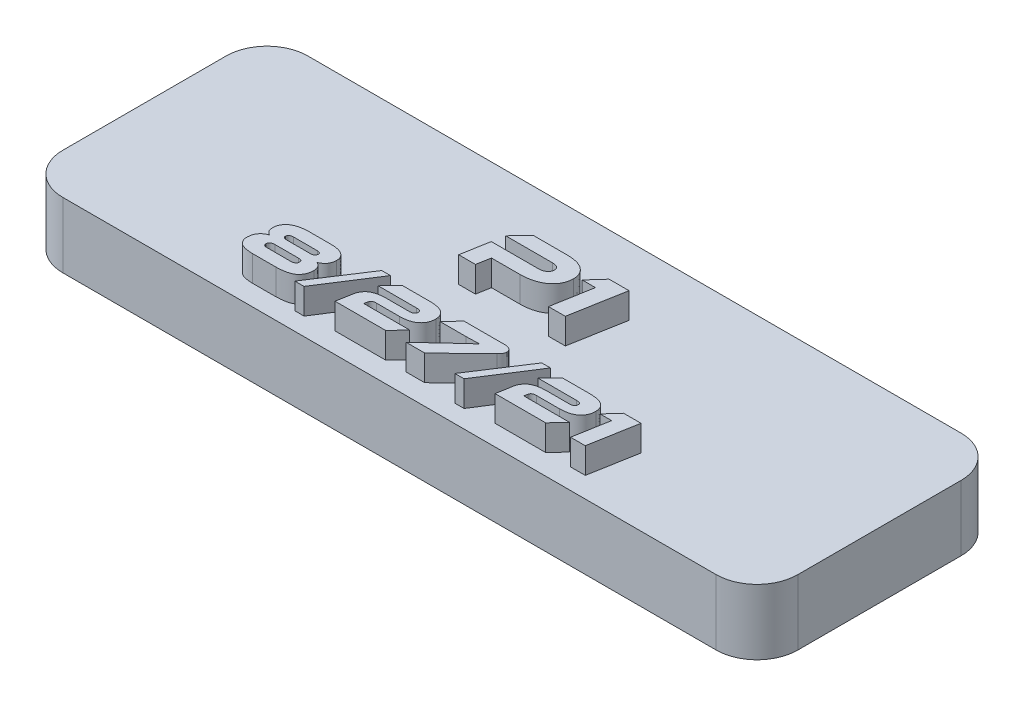
from build123d import *

# Parameters (mm, degrees)
SKETCH1_W           = 57.15
SKETCH1_H           = 19.05
BOSS_EXTRUDE1_DEPTH = 5.08
FILLET1_R           = 3.175
BOSS_EXTRUDE2_DEPTH = 2
SKETCH4_R           = 0.9
CUT_EXTRUDE1_DEPTH  = 4


with BuildPart() as part:
    # Sketch1 → Boss-Extrude1 (new body)
    with BuildSketch(Plane(origin=(0, 0, 0), x_dir=(1, 0, 0), z_dir=(0, 1, 0))):
        Rectangle(SKETCH1_W, SKETCH1_H)
    extrude(amount=BOSS_EXTRUDE1_DEPTH)

    # Fillet1
    fillet1_edges = [part.edges().sort_by_distance(p)[0] for p in [
        (-28.575, 2.54, -9.525),
        (-28.575, 2.54, 9.525),
        (28.575, 2.54, 9.525),
        (28.575, 2.54, -9.525),
    ]]
    fillet(fillet1_edges, radius=FILLET1_R)

    # Sketch3 → Boss-Extrude2 (add)
    with BuildSketch(Plane(origin=(0, 5.08, 0), x_dir=(1, 0, 0), z_dir=(0, 1, 0))):
        Polygon((2.351478779, 3.106887389), (3.38143283, 3.106887389), (2.831702754, 0.003655726), (4.139681211, 0.003655726), (4.891610855, 4.206347541), (3.343520411, 4.206347541), align=None)
        with BuildLine():
            add(Edge.make_bspline(
                [(1.93617942, 2.8527417), (1.934548001, 2.90231375), (1.931341466, 2.999746992), (1.907592721, 3.14197663), (1.871533972, 3.277108946), (1.820217864, 3.404564931), (1.752466709, 3.52306029), (1.671452907, 3.634253816), (1.576803173, 3.738655138), (1.466524316, 3.833025271), (1.343731729, 3.919798167), (1.206638071, 3.99434896), (1.056874424, 4.058920389), (0.893276042, 4.110009865), (0.717507562, 4.152486481), (0.528579563, 4.182135489), (0.32669053, 4.200187529), (0.187743903, 4.204039197), (0.116097633, 4.206025266)],
                knots=[0, 0, 0, 0, 0.000148656, 0.000292181, 0.000431448, 0.000567592, 0.000703091, 0.000839863, 0.000979636, 0.0011248, 0.001274431, 0.001429905, 0.001592071, 0.00176293, 0.001943415, 0.002134132, 0.002336075, 0.002551059, 0.002551059, 0.002551059, 0.002551059], degree=3))
            Line((0.116097633, 4.206025266), (-2.537486027, 4.206347541))
            Line((-2.537486027, 4.206347541), (-3.59903376, 3.106887389))
            Line((-3.59903376, 3.106887389), (0.040558468, 3.106887389))
            add(Edge.make_bspline(
                [(0.040558468, 3.106887389), (0.083800572, 3.105271439), (0.16512106, 3.102232508), (0.279389455, 3.082562512), (0.377496994, 3.049448147), (0.458806589, 3.002533217), (0.522567826, 2.944054673), (0.569208403, 2.875128596), (0.597653204, 2.795454755), (0.600805832, 2.738736187), (0.602427874, 2.709554203)],
                knots=[0, 0, 0, 0, 0.000129715, 0.000243941, 0.000346575, 0.000438764, 0.000523505, 0.000603877, 0.000686278, 0.000773603, 0.000773603, 0.000773603, 0.000773603], degree=3))
            add(Edge.make_bspline(
                [(0.602427874, 2.709554203), (0.601617757, 2.68940885), (0.600038197, 2.650129607), (0.590824218, 2.592714955), (0.575293267, 2.538325425), (0.552998975, 2.486997986), (0.525702861, 2.438376615), (0.492263664, 2.39293274), (0.452571978, 2.350727054), (0.391094187, 2.297975724), (0.300068742, 2.241909704), (0.172768622, 2.194774305), (0.027308671, 2.164290223), (-0.076318985, 2.160374672), (-0.130724106, 2.158318986)],
                knots=[0, 0, 0, 0, 6.0445e-05, 0.000117855, 0.000173984, 0.00022968, 0.000285354, 0.000340937, 0.0003985, 0.000458785, 0.000583594, 0.000716696, 0.00086425, 0.001027338, 0.001027338, 0.001027338, 0.001027338], degree=3))
            Line((-0.130724106, 2.158318986), (-3.769639646, 2.158641261))
            Line((-3.769639646, 2.158641261), (-4.148763836, 0.003655726))
            Line((-4.148763836, 0.003655726), (-2.847104116, 0.003655726))
            Line((-2.847104116, 0.003655726), (-2.657542021, 1.059182001))
            Line((-2.657542021, 1.059182001), (-0.445984243, 1.059182001))
            add(Edge.make_bspline(
                [(-0.445984243, 1.059182001), (-0.355749246, 1.061335988), (-0.180027415, 1.065530619), (0.075339555, 1.093356204), (0.31644848, 1.132182566), (0.541787386, 1.189220643), (0.753130399, 1.259358952), (0.949049459, 1.345243266), (1.130241685, 1.445895761), (1.295098184, 1.561391424), (1.443032682, 1.688577723), (1.571880006, 1.826902301), (1.683038427, 1.973467635), (1.77282972, 2.131094192), (1.844045085, 2.29789434), (1.894889478, 2.47443279), (1.927807698, 2.660218917), (1.933355834, 2.787424299), (1.93617942, 2.8527417)],
                knots=[0, 0, 0, 0, 0.000270666, 0.000527089, 0.000769951, 0.001002752, 0.001223611, 0.001437281, 0.001643542, 0.001844398, 0.002040129, 0.002227698, 0.002410529, 0.002590701, 0.002770513, 0.002953344, 0.003140755, 0.003334978, 0.003334978, 0.003334978, 0.003334978], degree=3))
        make_face()
        Polygon((12.065708376, -5.218973535), (12.96691817, -5.218973535), (12.485904354, -7.93430124), (13.630385504, -7.93430124), (14.288323943, -4.256945902), (12.933744804, -4.256945902), align=None)
        with BuildLine():
            Line((7.249099263, -5.218973535), (10.240231157, -5.218973535))
            add(Edge.make_bspline(
                [(10.240231157, -5.218973535), (10.267932071, -5.218922741), (10.319778446, -5.218827674), (10.392507449, -5.225918073), (10.45403149, -5.242216387), (10.505862027, -5.26353583), (10.545955417, -5.294908436), (10.574269416, -5.334273792), (10.591821393, -5.381008794), (10.593046093, -5.4147712), (10.593680459, -5.432259348)],
                knots=[0, 0, 0, 0, 8.3099e-05, 0.000155531, 0.000218392, 0.000273538, 0.000322508, 0.000368908, 0.000417497, 0.000469711, 0.000469711, 0.000469711, 0.000469711], degree=3))
            add(Edge.make_bspline(
                [(10.593680459, -5.432259348), (10.593040666, -5.458018948), (10.591831061, -5.506720508), (10.571268675, -5.573936821), (10.537982299, -5.630194031), (10.488768676, -5.673414306), (10.425237577, -5.704561408), (10.34750341, -5.726311626), (10.254378251, -5.738498194), (10.187376606, -5.73961472), (10.151343907, -5.740215175)],
                knots=[0, 0, 0, 0, 7.6993e-05, 0.000145564, 0.000208395, 0.000270703, 0.000339032, 0.00041902, 0.000511893, 0.000619952, 0.000619952, 0.000619952, 0.000619952], degree=3))
            Line((10.151343907, -5.740215175), (8.393580413, -5.739416071))
            add(Edge.make_bspline(
                [(8.393580413, -5.739416071), (8.337978257, -5.740560639), (8.229725095, -5.742789025), (8.071729769, -5.753609346), (7.923010409, -5.772857955), (7.783387541, -5.798779792), (7.653124343, -5.833149331), (7.532045491, -5.875619954), (7.419778111, -5.92500466), (7.316576243, -5.98174212), (7.223107046, -6.047028209), (7.138581553, -6.120143527), (7.063180944, -6.201107035), (6.997179922, -6.289606037), (6.940798349, -6.385733808), (6.893702594, -6.489539314), (6.854755231, -6.600822081), (6.837433555, -6.678800473), (6.828620513, -6.718474855)],
                knots=[0, 0, 0, 0, 0.000166829, 0.000324804, 0.000474816, 0.000616477, 0.000750546, 0.000878553, 0.001001026, 0.001118108, 0.001231277, 0.001342418, 0.001452782, 0.001562526, 0.00167296, 0.001786425, 0.001904052, 0.002025887, 0.002025887, 0.002025887, 0.002025887], degree=3))
            Line((6.828620513, -6.718474855), (6.613276402, -7.932183575))
            Line((6.613276402, -7.932183575), (10.549849246, -7.932183575))
            Line((10.549849246, -7.932183575), (11.456587935, -6.970155942))
            Line((11.456587935, -6.970155942), (7.884922124, -6.970155942))
            Line((7.884922124, -6.970155942), (7.934682174, -6.707239748))
            add(Edge.make_bspline(
                [(7.934682174, -6.707239748), (7.938459698, -6.686112106), (7.945782455, -6.645156023), (7.974493808, -6.590591717), (8.012854501, -6.543848716), (8.064193832, -6.508043577), (8.125269299, -6.47963759), (8.197586919, -6.461031101), (8.28065034, -6.450993538), (8.339573851, -6.450679637), (8.370799306, -6.450513291)],
                knots=[0, 0, 0, 0, 6.4036e-05, 0.000124134, 0.000182613, 0.000243892, 0.000310094, 0.000383827, 0.000466868, 0.000560486, 0.000560486, 0.000560486, 0.000560486], degree=3))
            Line((8.370799306, -6.450513291), (10.129653268, -6.449714187))
            add(Edge.make_bspline(
                [(10.129653268, -6.449714187), (10.195334293, -6.448593152), (10.322668734, -6.446419826), (10.506566583, -6.426694059), (10.677983193, -6.400940141), (10.835830079, -6.361961645), (10.981584073, -6.315052912), (11.112925328, -6.255202462), (11.232398443, -6.187512089), (11.337110883, -6.107690588), (11.429694075, -6.020066732), (11.510150437, -5.925525662), (11.577929321, -5.823724541), (11.633682123, -5.715194429), (11.675818093, -5.599220599), (11.706513528, -5.476792913), (11.724168874, -5.347458364), (11.726121827, -5.259004345), (11.72711788, -5.21389067)],
                knots=[0, 0, 0, 0, 0.00019697, 0.000381861, 0.000554393, 0.000716581, 0.000869107, 0.001013024, 0.00114885, 0.001280192, 0.001406932, 0.001530654, 0.001651783, 0.001773055, 0.001895792, 0.002021116, 0.002151095, 0.002286391, 0.002286391, 0.002286391, 0.002286391], degree=3))
            add(Edge.make_bspline(
                [(11.72711788, -5.21389067), (11.726665426, -5.1780961), (11.725779681, -5.108023129), (11.709569834, -5.005989197), (11.685577761, -4.909275966), (11.649043058, -4.818686266), (11.601408705, -4.734234215), (11.543329663, -4.655338408), (11.474962037, -4.582231577), (11.395667596, -4.515185386), (11.30484468, -4.455053695), (11.201266059, -4.402688892), (11.085032939, -4.359688685), (10.956845459, -4.322394884), (10.81604245, -4.294289614), (10.662695405, -4.27367202), (10.496828874, -4.26108405), (10.381999258, -4.258543735), (10.322519354, -4.257227893)],
                knots=[0, 0, 0, 0, 0.000107259, 0.000209975, 0.000309113, 0.00040566, 0.000501999, 0.00059927, 0.000698874, 0.0008016, 0.000910084, 0.001024914, 0.001148961, 0.001281358, 0.001425053, 0.00157924, 0.00174531, 0.001923772, 0.001923772, 0.001923772, 0.001923772], degree=3))
            Line((10.322519354, -4.257227893), (8.155837952, -4.256945902))
            Line((8.155837952, -4.256945902), (7.249099263, -5.218973535))
        make_face()
        Polygon((6.363288822, -4.05005839), (3.6983617, -8.139071868), (4.411589084, -8.139071868), (7.037813944, -4.05005839), align=None)
        with BuildLine():
            add(Edge.make_bspline(
                [(4.004777123, -5.174742379), (4.029024924, -5.151407477), (4.075084578, -5.107081907), (4.133832491, -5.037795203), (4.183044922, -4.973592199), (4.218797102, -4.910813811), (4.244419839, -4.850938085), (4.26356591, -4.793598023), (4.274499344, -4.737589122), (4.275096894, -4.700673401), (4.275386745, -4.682766854)],
                knots=[0, 0, 0, 0, 0.000100886, 0.000191637, 0.000272267, 0.000343204, 0.000407693, 0.000467391, 0.00052434, 0.000577986, 0.000577986, 0.000577986, 0.000577986], degree=3))
            add(Edge.make_bspline(
                [(4.275386745, -4.682766854), (4.274105021, -4.653486042), (4.271604974, -4.596372839), (4.244347939, -4.515030234), (4.201389494, -4.441668447), (4.140498426, -4.377151224), (4.061881378, -4.323583567), (3.963749057, -4.286858509), (3.849111691, -4.26283551), (3.766531073, -4.259173221), (3.722666027, -4.257227893)],
                knots=[0, 0, 0, 0, 8.7554e-05, 0.000170776, 0.000254321, 0.000340905, 0.000434751, 0.000537092, 0.000653183, 0.000784715, 0.000784715, 0.000784715, 0.000784715], degree=3))
            Line((3.722666027, -4.257227893), (0.527102518, -4.256945902))
            Line((0.527102518, -4.256945902), (-0.374107276, -5.218973535))
            Line((-0.374107276, -5.218973535), (1.632881407, -5.218973535))
            add(Edge.make_bspline(
                [(1.632881407, -5.218973535), (1.699967086, -5.218997568), (1.826513686, -5.219042903), (2.004251891, -5.217329053), (2.158370141, -5.215074947), (2.290888321, -5.211837), (2.40608795, -5.20798232), (2.50817269, -5.202736075), (2.599185808, -5.198744057), (2.656164158, -5.19380437), (2.682815181, -5.191493883)],
                knots=[0, 0, 0, 0, 0.000201256, 0.000379637, 0.000533234, 0.000663655, 0.000777309, 0.000879007, 0.000970321, 0.001050565, 0.001050565, 0.001050565, 0.001050565], degree=3))
            add(Edge.make_bspline(
                [(2.682815181, -5.191493883), (2.662403763, -5.207311492), (2.61851047, -5.241326128), (2.551140649, -5.300111931), (2.472962269, -5.364613541), (2.404091254, -5.426820766), (2.342672509, -5.481639275), (2.291011702, -5.529231357), (2.232866015, -5.57975307), (2.171647286, -5.637277131), (2.104339911, -5.69844842), (2.032438422, -5.764936183), (1.955623726, -5.836098298), (1.902913077, -5.885245979), (1.875730948, -5.910590737)],
                knots=[0, 0, 0, 0, 7.7453e-05, 0.000166556, 0.000268154, 0.000381479, 0.000444917, 0.000515134, 0.000592189, 0.000675968, 0.000767116, 0.000865046, 0.000969757, 0.001081252, 0.001081252, 0.001081252, 0.001081252], degree=3))
            Line((1.875730948, -5.910590737), (-0.296702754, -7.93430124))
            Line((-0.296702754, -7.93430124), (1.146338696, -7.93430124))
            Line((1.146338696, -7.93430124), (4.004777123, -5.174742379))
        make_face()
        with BuildLine():
            Line((-5.190716389, -5.218973535), (-2.199584495, -5.218973535))
            add(Edge.make_bspline(
                [(-2.199584495, -5.218973535), (-2.171883581, -5.218922741), (-2.120037206, -5.218827674), (-2.047308203, -5.225918073), (-1.985784162, -5.242216387), (-1.933953625, -5.26353583), (-1.893860236, -5.294908436), (-1.865546236, -5.334273792), (-1.847994259, -5.381008794), (-1.846769559, -5.4147712), (-1.846135193, -5.432259348)],
                knots=[0, 0, 0, 0, 8.3099e-05, 0.000155531, 0.000218392, 0.000273538, 0.000322508, 0.000368908, 0.000417497, 0.000469711, 0.000469711, 0.000469711, 0.000469711], degree=3))
            add(Edge.make_bspline(
                [(-1.846135193, -5.432259348), (-1.846774987, -5.458018948), (-1.847984591, -5.506720508), (-1.868546977, -5.573936821), (-1.901833353, -5.630194031), (-1.951046976, -5.673414306), (-2.014578075, -5.704561408), (-2.092312242, -5.726311626), (-2.185437401, -5.738498194), (-2.252439046, -5.73961472), (-2.288471745, -5.740215175)],
                knots=[0, 0, 0, 0, 7.6993e-05, 0.000145564, 0.000208395, 0.000270703, 0.000339032, 0.00041902, 0.000511893, 0.000619952, 0.000619952, 0.000619952, 0.000619952], degree=3))
            Line((-2.288471745, -5.740215175), (-4.046235239, -5.739416071))
            add(Edge.make_bspline(
                [(-4.046235239, -5.739416071), (-4.101837395, -5.740560639), (-4.210090557, -5.742789025), (-4.368085884, -5.753609346), (-4.516805243, -5.772857955), (-4.656428111, -5.798779792), (-4.786691309, -5.833149331), (-4.907770161, -5.875619954), (-5.020037542, -5.92500466), (-5.123239409, -5.98174212), (-5.216708606, -6.047028209), (-5.301234099, -6.120143527), (-5.376634708, -6.201107035), (-5.44263573, -6.289606037), (-5.499017304, -6.385733808), (-5.546113058, -6.489539314), (-5.585060422, -6.600822081), (-5.602382098, -6.678800473), (-5.611195139, -6.718474855)],
                knots=[0, 0, 0, 0, 0.000166829, 0.000324804, 0.000474816, 0.000616477, 0.000750546, 0.000878553, 0.001001026, 0.001118108, 0.001231277, 0.001342418, 0.001452782, 0.001562526, 0.00167296, 0.001786425, 0.001904052, 0.002025887, 0.002025887, 0.002025887, 0.002025887], degree=3))
            Line((-5.611195139, -6.718474855), (-5.82653925, -7.932183575))
            Line((-5.82653925, -7.932183575), (-1.889966406, -7.932183575))
            Line((-1.889966406, -7.932183575), (-0.983227717, -6.970155942))
            Line((-0.983227717, -6.970155942), (-4.554893528, -6.970155942))
            Line((-4.554893528, -6.970155942), (-4.505133478, -6.707239748))
            add(Edge.make_bspline(
                [(-4.505133478, -6.707239748), (-4.501355954, -6.686112106), (-4.494033197, -6.645156023), (-4.465321844, -6.590591717), (-4.426961151, -6.543848716), (-4.37562182, -6.508043577), (-4.314546353, -6.47963759), (-4.242228733, -6.461031101), (-4.159165312, -6.450993538), (-4.100241801, -6.450679637), (-4.069016347, -6.450513291)],
                knots=[0, 0, 0, 0, 6.4036e-05, 0.000124134, 0.000182613, 0.000243892, 0.000310094, 0.000383827, 0.000466868, 0.000560486, 0.000560486, 0.000560486, 0.000560486], degree=3))
            Line((-4.069016347, -6.450513291), (-2.310162384, -6.449714187))
            add(Edge.make_bspline(
                [(-2.310162384, -6.449714187), (-2.244481359, -6.448593152), (-2.117146918, -6.446419826), (-1.933249069, -6.426694059), (-1.761832459, -6.400940141), (-1.603985573, -6.361961645), (-1.458231579, -6.315052912), (-1.326890324, -6.255202462), (-1.207417209, -6.187512089), (-1.102704769, -6.107690588), (-1.010121577, -6.020066732), (-0.929665216, -5.925525662), (-0.861886331, -5.823724541), (-0.806133529, -5.715194429), (-0.76399756, -5.599220599), (-0.733302124, -5.476792913), (-0.715646779, -5.347458364), (-0.713693825, -5.259004345), (-0.712697772, -5.21389067)],
                knots=[0, 0, 0, 0, 0.00019697, 0.000381861, 0.000554393, 0.000716581, 0.000869107, 0.001013024, 0.00114885, 0.001280192, 0.001406932, 0.001530654, 0.001651783, 0.001773055, 0.001895792, 0.002021116, 0.002151095, 0.002286391, 0.002286391, 0.002286391, 0.002286391], degree=3))
            add(Edge.make_bspline(
                [(-0.712697772, -5.21389067), (-0.713150227, -5.1780961), (-0.714035971, -5.108023129), (-0.730245819, -5.005989197), (-0.754237891, -4.909275966), (-0.790772594, -4.818686266), (-0.838406947, -4.734234215), (-0.896485989, -4.655338408), (-0.964853616, -4.582231577), (-1.044148056, -4.515185386), (-1.134970973, -4.455053695), (-1.238549593, -4.402688892), (-1.354782714, -4.359688685), (-1.482970193, -4.322394884), (-1.623773202, -4.294289614), (-1.777120248, -4.27367202), (-1.942986778, -4.26108405), (-2.057816394, -4.258543735), (-2.117296298, -4.257227893)],
                knots=[0, 0, 0, 0, 0.000107259, 0.000209975, 0.000309113, 0.00040566, 0.000501999, 0.00059927, 0.000698874, 0.0008016, 0.000910084, 0.001024914, 0.001148961, 0.001281358, 0.001425053, 0.00157924, 0.00174531, 0.001923772, 0.001923772, 0.001923772, 0.001923772], degree=3))
            Line((-2.117296298, -4.257227893), (-4.2839777, -4.256945902))
            Line((-4.2839777, -4.256945902), (-5.190716389, -5.218973535))
        make_face()
        Polygon((-6.07652683, -4.05005839), (-8.741453952, -8.139071868), (-8.028226569, -8.139071868), (-5.402001708, -4.05005839), align=None)
        with BuildLine():
            add(Edge.make_bspline(
                [(-10.422687798, -7.932183575), (-10.381026241, -7.931231171), (-10.299056591, -7.929357303), (-10.178415393, -7.92303202), (-10.062958982, -7.913299393), (-9.952718582, -7.901630571), (-9.847962475, -7.886120178), (-9.748040432, -7.869023985), (-9.653663148, -7.848038176), (-9.564788922, -7.824924016), (-9.481076561, -7.79951071), (-9.402772047, -7.770456276), (-9.328975458, -7.739757788), (-9.261026887, -7.705166947), (-9.198030224, -7.668342595), (-9.140604301, -7.628415757), (-9.088253019, -7.586096005), (-9.026969014, -7.52618861), (-8.958903826, -7.44788067), (-8.888169526, -7.349322028), (-8.829247253, -7.24731168), (-8.782732619, -7.14179993), (-8.74706266, -7.033385143), (-8.723846323, -6.921252912), (-8.71239672, -6.805633592), (-8.713959642, -6.727559312), (-8.71474997, -6.688079215)],
                knots=[0, 0, 0, 0, 0.000125013, 0.000245965, 0.000362345, 0.000472585, 0.000578466, 0.000679988, 0.000776639, 0.000868406, 0.000955443, 0.001038954, 0.001118882, 0.001195077, 0.00126751, 0.001337627, 0.001404712, 0.001469201, 0.001594487, 0.00171546, 0.001832632, 0.001947228, 0.002060803, 0.002174381, 0.002290108, 0.002408491, 0.002408491, 0.002408491, 0.002408491], degree=3))
            add(Edge.make_bspline(
                [(-8.71474997, -6.688079215), (-8.716718868, -6.645013118), (-8.720507981, -6.562133096), (-8.745726424, -6.444672392), (-8.784385739, -6.339091581), (-8.840477482, -6.248261694), (-8.908160225, -6.170723555), (-8.985883496, -6.10705473), (-9.072428666, -6.055649416), (-9.136061149, -6.034755311), (-9.168284915, -6.024174444)],
                knots=[0, 0, 0, 0, 0.000129139, 0.000248525, 0.000358904, 0.000464809, 0.000566844, 0.000666291, 0.000765209, 0.000866693, 0.000866693, 0.000866693, 0.000866693], degree=3))
            add(Edge.make_bspline(
                [(-9.168284915, -6.024174444), (-9.12695426, -6.009960653), (-9.043670109, -5.981318874), (-8.927209945, -5.914739414), (-8.817482937, -5.831227741), (-8.732658249, -5.748532962), (-8.671267178, -5.672798575), (-8.629940113, -5.610121102), (-8.595852381, -5.541280496), (-8.566206446, -5.468161351), (-8.542694641, -5.389726388), (-8.526641806, -5.306040388), (-8.513930952, -5.217443624), (-8.511316318, -5.156345524), (-8.509979342, -5.125103406)],
                knots=[0, 0, 0, 0, 0.000130881, 0.000263734, 0.000400196, 0.000543864, 0.000617818, 0.000692362, 0.000768557, 0.000847875, 0.000928857, 0.001013724, 0.001103318, 0.001197072, 0.001197072, 0.001197072, 0.001197072], degree=3))
            add(Edge.make_bspline(
                [(-8.509979342, -5.125103406), (-8.511199677, -5.090349443), (-8.513572305, -5.022779311), (-8.532271978, -4.92500398), (-8.558784039, -4.833420282), (-8.596756966, -4.748206931), (-8.646126762, -4.670138756), (-8.705594903, -4.59864822), (-8.775643685, -4.533829851), (-8.855514218, -4.475835581), (-8.94503863, -4.424616933), (-9.042894783, -4.38005075), (-9.148734503, -4.341545727), (-9.262984099, -4.310438157), (-9.385455195, -4.286642109), (-9.516151426, -4.270305953), (-9.65470961, -4.259700382), (-9.749781358, -4.258066688), (-9.798594505, -4.257227893)],
                knots=[0, 0, 0, 0, 0.000104182, 0.000202555, 0.000297711, 0.000389729, 0.000481385, 0.000573968, 0.000667919, 0.000766953, 0.000869442, 0.000976817, 0.001089166, 0.001206956, 0.001331669, 0.001463128, 0.001601898, 0.001748332, 0.001748332, 0.001748332, 0.001748332], degree=3))
            Line((-9.798594505, -4.257227893), (-11.550582265, -4.256945902))
            add(Edge.make_bspline(
                [(-11.550582265, -4.256945902), (-11.611856279, -4.257933345), (-11.731192804, -4.259856478), (-11.905553317, -4.27445031), (-12.070118963, -4.298184588), (-12.225137743, -4.330928531), (-12.370534395, -4.372216855), (-12.506311014, -4.423370326), (-12.632295363, -4.48435463), (-12.748508555, -4.553771073), (-12.85390852, -4.631408275), (-12.944756782, -4.719750309), (-13.023615229, -4.815062538), (-13.086987815, -4.920560106), (-13.137753324, -5.033834732), (-13.174495943, -5.155860959), (-13.198106793, -5.286067538), (-13.202340068, -5.375899516), (-13.204505966, -5.421860839)],
                knots=[0, 0, 0, 0, 0.000183805, 0.000357976, 0.000524491, 0.000682313, 0.000832949, 0.000977498, 0.00111702, 0.001252279, 0.00138314, 0.001508725, 0.001631528, 0.001753207, 0.001876737, 0.002003, 0.002134641, 0.002272556, 0.002272556, 0.002272556, 0.002272556], degree=3))
            add(Edge.make_bspline(
                [(-13.204505966, -5.421860839), (-13.202345014, -5.460637769), (-13.19820898, -5.534856314), (-13.175711038, -5.640394087), (-13.139872352, -5.734319484), (-13.090614402, -5.816044843), (-13.030789162, -5.884580779), (-12.965381891, -5.942717951), (-12.894985912, -5.991372439), (-12.843133463, -6.0132839), (-12.817361498, -6.024174444)],
                knots=[0, 0, 0, 0, 0.00011638, 0.00022275, 0.000322273, 0.000416653, 0.000507404, 0.000594091, 0.000678837, 0.000762581, 0.000762581, 0.000762581, 0.000762581], degree=3))
            add(Edge.make_bspline(
                [(-12.817361498, -6.024174444), (-12.842290131, -6.030958114), (-12.891984718, -6.044481183), (-12.964076134, -6.072159226), (-13.033661461, -6.104472842), (-13.099811435, -6.143792742), (-13.163829319, -6.187363466), (-13.224779575, -6.237488578), (-13.283221467, -6.292639194), (-13.338523739, -6.353238645), (-13.388944119, -6.419812547), (-13.434192695, -6.491713486), (-13.471403195, -6.570185197), (-13.503873411, -6.65334551), (-13.528505388, -6.742945011), (-13.546272257, -6.837982222), (-13.559930977, -6.93861072), (-13.562390631, -7.007719051), (-13.56365445, -7.043228273)],
                knots=[0, 0, 0, 0, 7.7461e-05, 0.000154416, 0.000231347, 0.000307349, 0.000385003, 0.000463457, 0.000543805, 0.000625913, 0.000709263, 0.000794051, 0.000880268, 0.000969397, 0.001061581, 0.001158529, 0.001259331, 0.001365863, 0.001365863, 0.001365863, 0.001365863], degree=3))
            add(Edge.make_bspline(
                [(-13.56365445, -7.043228273), (-13.563480868, -7.074984833), (-13.563141249, -7.137117687), (-13.552008838, -7.228477712), (-13.530331937, -7.315193082), (-13.498741144, -7.397544917), (-13.457987218, -7.475819019), (-13.406134165, -7.548574193), (-13.345452427, -7.617378923), (-13.274939945, -7.681696438), (-13.192115461, -7.740249013), (-13.095428854, -7.790386011), (-12.98457345, -7.832290641), (-12.860552837, -7.868255087), (-12.722460083, -7.895907325), (-12.570851714, -7.91498255), (-12.405678506, -7.929258288), (-12.290803934, -7.931522719), (-12.231045598, -7.932700688)],
                knots=[0, 0, 0, 0, 9.5217e-05, 0.000186295, 0.000275341, 0.00036269, 0.000450349, 0.000539338, 0.000630011, 0.000725141, 0.000825008, 0.000933418, 0.001050917, 0.001180018, 0.001320418, 0.001472913, 0.00163825, 0.001817512, 0.001817512, 0.001817512, 0.001817512], degree=3))
            Line((-12.231045598, -7.932700688), (-10.422687798, -7.932183575))
        make_face()
        with BuildLine():
            add(Edge.make_bspline(
                [(-10.162829759, -6.449714187), (-10.137359923, -6.450481454), (-10.089745329, -6.451915822), (-10.023292614, -6.462295382), (-9.966873341, -6.478314967), (-9.920209872, -6.501735345), (-9.883969551, -6.532597578), (-9.857975947, -6.570559095), (-9.844204887, -6.615980043), (-9.843146484, -6.647995141), (-9.842588194, -6.664882542)],
                knots=[0, 0, 0, 0, 7.6381e-05, 0.000142791, 0.000201248, 0.000251692, 0.000298195, 0.000342566, 0.000387849, 0.000438401, 0.000438401, 0.000438401, 0.000438401], degree=3))
            add(Edge.make_bspline(
                [(-9.842588194, -6.664882542), (-9.843067544, -6.688226141), (-9.843983356, -6.732824723), (-9.863166806, -6.795373302), (-9.894793835, -6.849206592), (-9.941193171, -6.892724618), (-9.999892308, -6.927750857), (-10.072805929, -6.950290013), (-10.15754875, -6.966886823), (-10.218701661, -6.969202952), (-10.251329565, -6.970438714)],
                knots=[0, 0, 0, 0, 6.9755e-05, 0.000133269, 0.000193903, 0.000254998, 0.000322079, 0.000397205, 0.000482702, 0.000580498, 0.000580498, 0.000580498, 0.000580498], degree=3))
            Line((-10.251329565, -6.970438714), (-12.064769448, -6.970155942))
            add(Edge.make_bspline(
                [(-12.064769448, -6.970155942), (-12.089839216, -6.969487722), (-12.136790458, -6.968236265), (-12.202132995, -6.958046297), (-12.257546169, -6.941463094), (-12.303690623, -6.918653153), (-12.339426023, -6.887523732), (-12.364107938, -6.849203004), (-12.379323818, -6.804370639), (-12.380175859, -6.772197033), (-12.380624143, -6.755269577)],
                knots=[0, 0, 0, 0, 7.5181e-05, 0.000140801, 0.000197728, 0.000248171, 0.000294073, 0.000338001, 0.000383531, 0.000434082, 0.000434082, 0.000434082, 0.000434082], degree=3))
            add(Edge.make_bspline(
                [(-12.380624143, -6.755269577), (-12.380391836, -6.731951284), (-12.379948611, -6.687461638), (-12.361903435, -6.624978081), (-12.330330671, -6.571485588), (-12.284937626, -6.527263189), (-12.225608383, -6.493624141), (-12.153698319, -6.470524019), (-12.069646205, -6.45409962), (-12.00903604, -6.451761428), (-11.976682083, -6.450513291)],
                knots=[0, 0, 0, 0, 6.9705e-05, 0.000132992, 0.000192528, 0.000254182, 0.000320856, 0.000395224, 0.000479936, 0.000576934, 0.000576934, 0.000576934, 0.000576934], degree=3))
            Line((-11.976682083, -6.450513291), (-10.162829759, -6.449714187))
        make_face(mode=Mode.SUBTRACT)
        with BuildLine():
            add(Edge.make_bspline(
                [(-9.919558404, -5.218973535), (-9.901592483, -5.219198427), (-9.866592572, -5.219636544), (-9.81595973, -5.228301012), (-9.768231871, -5.240368296), (-9.725462532, -5.25971699), (-9.687089986, -5.28343921), (-9.659939997, -5.318095563), (-9.642407304, -5.359573023), (-9.639395524, -5.389948541), (-9.637817566, -5.405863134)],
                knots=[0, 0, 0, 0, 5.3815e-05, 0.000104839, 0.000153737, 0.000201004, 0.000245375, 0.000287473, 0.000330852, 0.000378591, 0.000378591, 0.000378591, 0.000378591], degree=3))
            add(Edge.make_bspline(
                [(-9.637817566, -5.405863134), (-9.639676403, -5.430297574), (-9.64318995, -5.476483199), (-9.664809274, -5.54029414), (-9.701136496, -5.591806118), (-9.750158569, -5.630011869), (-9.807438924, -5.656042763), (-9.86976961, -5.675598553), (-9.937366587, -5.68684283), (-9.984126664, -5.687754153), (-10.008164444, -5.688222633)],
                knots=[0, 0, 0, 0, 7.3319e-05, 0.000138587, 0.0001994, 0.000259737, 0.000322704, 0.000387218, 0.000455335, 0.000527396, 0.000527396, 0.000527396, 0.000527396], degree=3))
            Line((-10.008164444, -5.688222633), (-11.854671459, -5.688222633))
            add(Edge.make_bspline(
                [(-11.854671459, -5.688222633), (-11.8732478, -5.688204865), (-11.909122062, -5.688170553), (-11.96080103, -5.679717041), (-12.008662403, -5.66640895), (-12.051529618, -5.646675592), (-12.089806016, -5.620784393), (-12.115394188, -5.58249431), (-12.133258041, -5.537200648), (-12.135480464, -5.503647002), (-12.136659136, -5.485851661)],
                knots=[0, 0, 0, 0, 5.5643e-05, 0.000107457, 0.00015657, 0.000204168, 0.000248805, 0.000292972, 0.000340064, 0.000393243, 0.000393243, 0.000393243, 0.000393243], degree=3))
            add(Edge.make_bspline(
                [(-12.136659136, -5.485851661), (-12.134529749, -5.462204608), (-12.130503401, -5.417491619), (-12.108221032, -5.356065551), (-12.070380012, -5.307302147), (-12.019982692, -5.272336123), (-11.962610033, -5.247888578), (-11.900859803, -5.229757796), (-11.834867719, -5.220335185), (-11.789535638, -5.219776221), (-11.766312258, -5.219489867)],
                knots=[0, 0, 0, 0, 7.1041e-05, 0.000134328, 0.000193048, 0.00025321, 0.000316233, 0.00037952, 0.00044581, 0.000515441, 0.000515441, 0.000515441, 0.000515441], degree=3))
            Line((-11.766312258, -5.219489867), (-9.919558404, -5.218973535))
        make_face(mode=Mode.SUBTRACT)
    extrude(amount=BOSS_EXTRUDE2_DEPTH)

    # Sketch4 → Cut-Extrude1 (cut)
    with BuildSketch(Plane.XZ):
        with Locations((-25.4, 0)):
            Circle(SKETCH4_R)
        with Locations((25.4, 0)):
            Circle(SKETCH4_R)
    extrude(amount=-CUT_EXTRUDE1_DEPTH, mode=Mode.SUBTRACT)


solid = part.part
